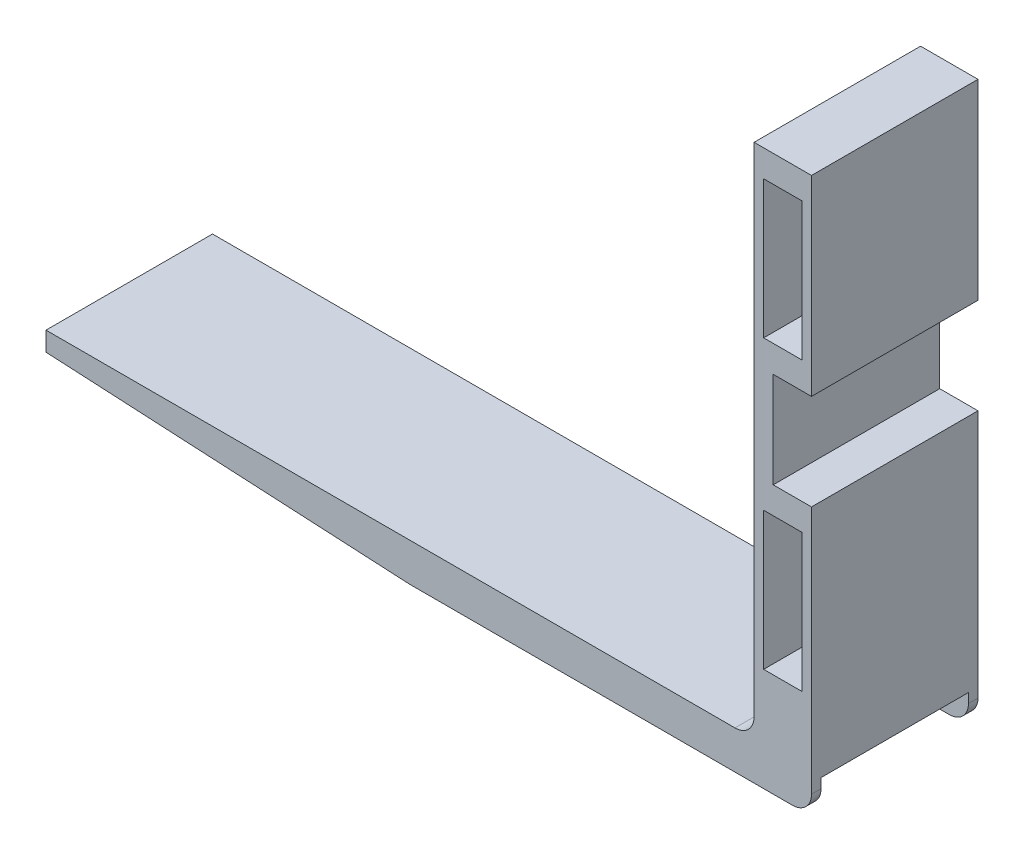
from build123d import *

# Parameters (mm, degrees)
SKETCH1_W           = 20
SKETCH1_H           = 72
BOSS_EXTRUDE2_DEPTH = 87
SKETCH2_W           = 77.037941343
SKETCH2_H           = 18.412852551
CUT_EXTRUDE1_DEPTH  = 420


with BuildPart() as part:
    # Sketch1 → Boss-Extrude2 (new body)
    with BuildSketch(Plane.XY):
        with BuildLine():
            Line((-202, -150.294090379), (-202, -140.294090379))
            Line((-202, -140.294090379), (148, -140.294090379))
            Line((148, -140.294090379), (158, -140.294090379))
            ThreePointArc((158, -140.294090379), (165.071067812, -137.36515819), (168, -130.294090379))
            Line((168, -130.294090379), (168, 129.705909621))
            Line((168, 129.705909621), (198, 129.705909621))
            Line((198, 129.705909621), (198, 29.705909621))
            Line((198, 29.705909621), (178, 29.705909621))
            Line((178, 29.705909621), (178, -20.294090379))
            Line((178, -20.294090379), (198, -20.294090379))
            Line((198, -20.294090379), (198, -150.294090379))
            ThreePointArc((198, -150.294090379), (195.071067812, -157.36515819), (188, -160.294090379))
            Line((188, -160.294090379), (-12, -160.294090379))
            Line((-12, -160.294090379), (-202, -150.294090379))
        make_face()
        with Locations((183, -70.294090379)):
            Rectangle(SKETCH1_W, SKETCH1_H, mode=Mode.SUBTRACT)
        with Locations((183, 79.705909621)):
            Rectangle(SKETCH1_W, SKETCH1_H, mode=Mode.SUBTRACT)
    extrude(amount=BOSS_EXTRUDE2_DEPTH)

    # Sketch2 → Cut-Extrude1 (cut)
    with BuildSketch(Plane.ZY.offset(202)):
        with Locations((43.518970671, -154.500516655)):
            Rectangle(SKETCH2_W, SKETCH2_H)
    extrude(amount=-CUT_EXTRUDE1_DEPTH, mode=Mode.SUBTRACT)


solid = part.part
